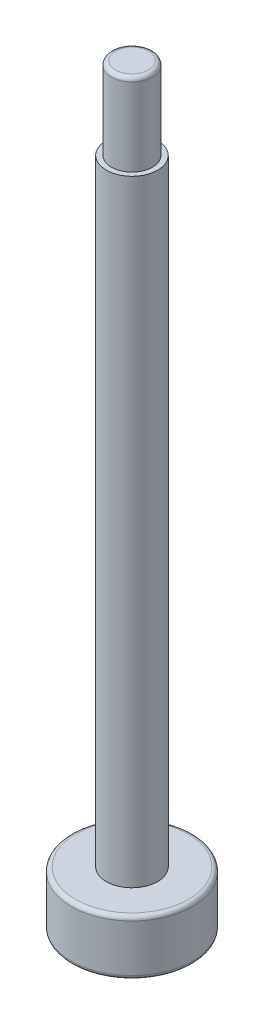
from build123d import *

# Parameters (mm, degrees)
SKETCH_1_R          = 2.95
EXTRUDE_1_DEPTH     = 2.7
SKETCH_2_R          = 1.25
EXTRUDE_2_DEPTH     = 30
SKETCH_3_R          = 1
EXTRUDE_3_DEPTH     = 4
CUT_EXTRUDE_1_DEPTH = 2
FILLET_1_R          = 0.2


with BuildPart() as part:
    # 草图1 → 凸台-拉伸1 (new body)
    with BuildSketch(Plane(origin=(0, 0, 0), x_dir=(1, 0, 0), z_dir=(0, 1, 0))):
        Circle(SKETCH_1_R)
    extrude(amount=EXTRUDE_1_DEPTH)

    # 草图2 → 凸台-拉伸2 (add)
    with BuildSketch(Plane(origin=(0, 2.7, 0), x_dir=(1, 0, 0), z_dir=(0, 1, 0))):
        Circle(SKETCH_2_R)
    extrude(amount=EXTRUDE_2_DEPTH)

    # 草图3 → 凸台-拉伸3 (add)
    with BuildSketch(Plane(origin=(0, 32.7, 0), x_dir=(1, 0, 0), z_dir=(0, 1, 0))):
        Circle(SKETCH_3_R)
    extrude(amount=EXTRUDE_3_DEPTH)

    # 草图4 → 切除-拉伸1 (cut)
    with BuildSketch(Plane.XZ):
        Polygon((2.247285488, -0.53201623), (1.584382314, 1.680198207), (-0.662903174, 2.212214437), (-2.247285488, 0.53201623), (-1.584382314, -1.680198207), (0.662903174, -2.212214437), align=None)
    extrude(amount=-CUT_EXTRUDE_1_DEPTH, mode=Mode.SUBTRACT)

    # 圆角1
    fillet_1_edges = [part.edges().sort_by_distance(p)[0] for p in [
        (-1, 36.7, 0),
        (-2.95, 0, 0),
        (-2.95, 2.7, 0),
    ]]
    fillet(fillet_1_edges, radius=FILLET_1_R)


solid = part.part
